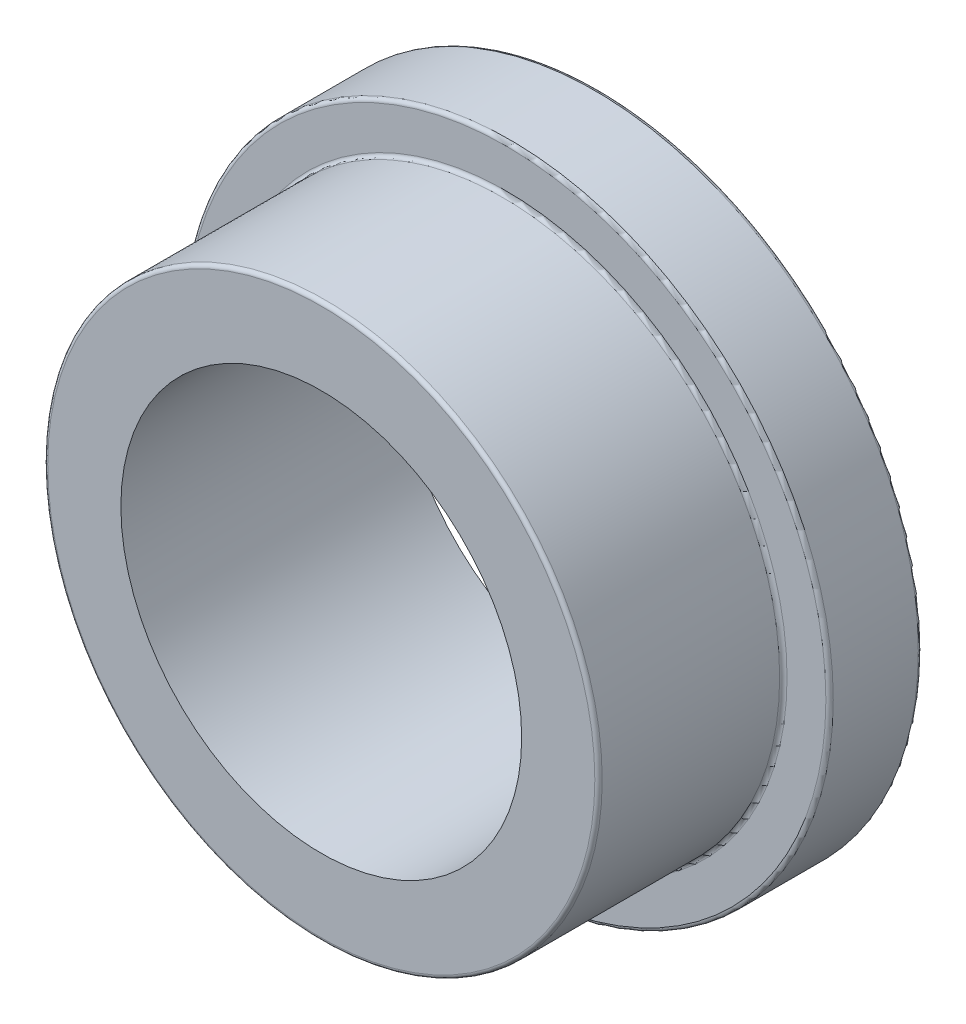
from build123d import *

# Parameters (mm, degrees)
MINOR_FILLET_SMOOTHING_R = 0.127


with BuildPart() as part:
    # Sketch1 → Revolve1 (revolve)
    with BuildSketch(Plane(origin=(0, 0, 0), x_dir=(1, 0, 0), z_dir=(0, 1, 0))):
        Polygon((6.885, -6.35), (9.525, -6.35), (9.525, 0), (11.1125, 0), (11.1125, 3.175), (6.885, 3.175), align=None)
    revolve(axis=Axis((0, 0, -3.175), (0, 0, 1)))

    # Minor Fillet Smoothing
    minor_fillet_smoothing_edges = [part.edges().sort_by_distance(p)[0] for p in [
        (-11.1125, 0, -3.175),
        (-11.1125, 0, 0),
        (-9.525, 0, 0),
        (-9.525, 0, 6.35),
    ]]
    fillet(minor_fillet_smoothing_edges, radius=MINOR_FILLET_SMOOTHING_R)


solid = part.part
